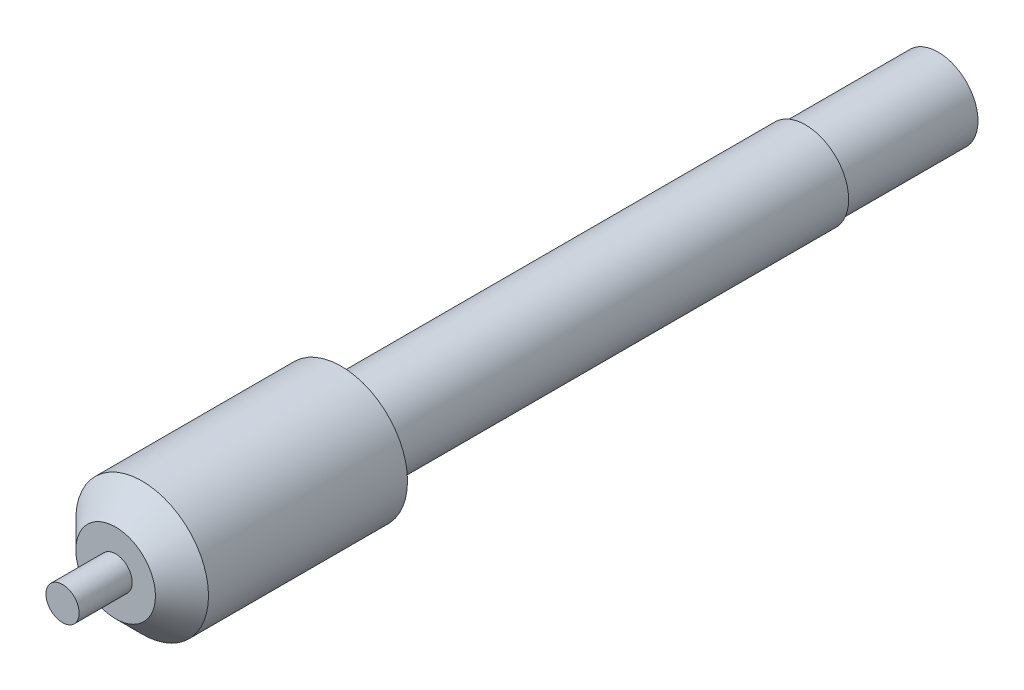
from build123d import *

# Parameters (mm, degrees)
CROQUIS1_R              = 3
SALIENTE_EXTRUIR1_DEPTH = 10
CROQUIS2_R              = 3.25
SALIENTE_EXTRUIR2_DEPTH = 35
CROQUIS3_R              = 5
SALIENTE_EXTRUIR3_DEPTH = 17
CHAFL_N1_SIZE           = 2
CROQUIS4_R              = 1.25
SALIENTE_EXTRUIR4_DEPTH = 4


with BuildPart() as part:
    # Croquis1 → Saliente-Extruir1 (new body)
    with BuildSketch(Plane.XY):
        Circle(CROQUIS1_R)
    extrude(amount=SALIENTE_EXTRUIR1_DEPTH)

    # Croquis2 → Saliente-Extruir2 (add)
    with BuildSketch(Plane.XY.offset(10)):
        Circle(CROQUIS2_R)
    extrude(amount=SALIENTE_EXTRUIR2_DEPTH)

    # Croquis3 → Saliente-Extruir3 (add)
    with BuildSketch(Plane.XY.offset(45)):
        Circle(CROQUIS3_R)
    extrude(amount=SALIENTE_EXTRUIR3_DEPTH)

    # Chaflán1
    chafl_n1_edges = [part.edges().sort_by_distance(p)[0] for p in [
        (-5, 0, 62),
    ]]
    chamfer(chafl_n1_edges, length=CHAFL_N1_SIZE)

    # Croquis4 → Saliente-Extruir4 (add)
    with BuildSketch(Plane.XY.offset(62)):
        Circle(CROQUIS4_R)
    extrude(amount=SALIENTE_EXTRUIR4_DEPTH)


solid = part.part
